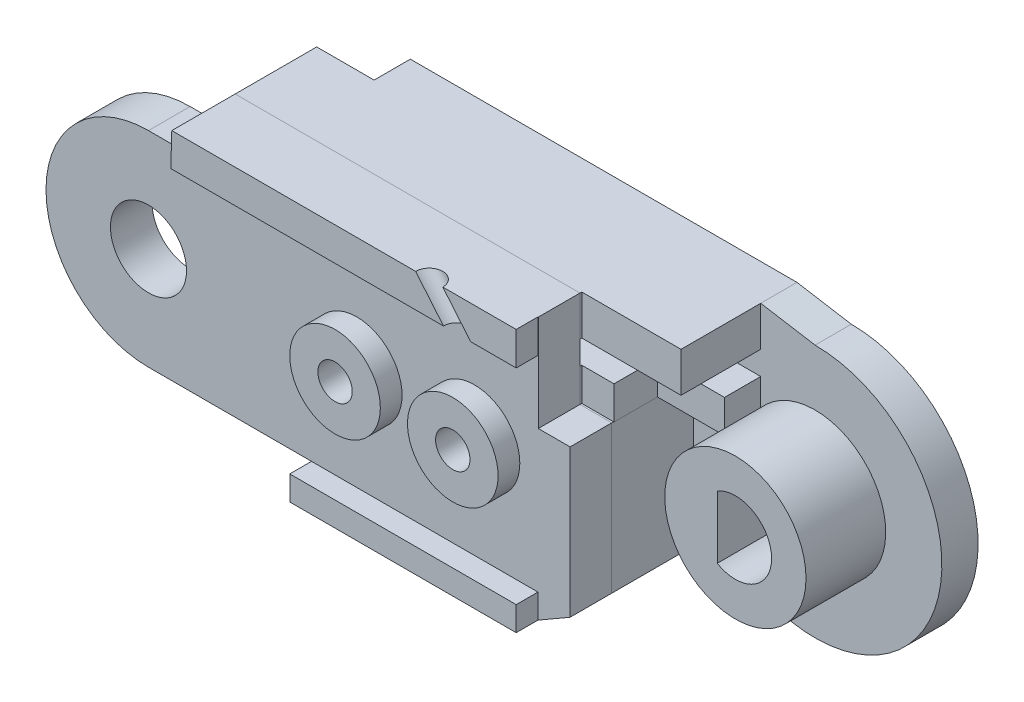
from build123d import *

# Parameters (mm, degrees)
BOSS_EXTRUDE1_DEPTH  = 2
BOSS_EXTRUDE6_DEPTH  = 4.5
CUT_EXTRUDE6_DEPTH   = 4.5
BOSS_EXTRUDE14_DEPTH = 2.3
SKETCH32_R           = 2.1
CUT_EXTRUDE7_DEPTH   = 2.3
SKETCH33_W           = 12.5
SKETCH33_H           = 1.343145751
BOSS_EXTRUDE15_DEPTH = 1.2
SKETCH35_W           = 5.479645997
SKETCH35_H           = 5.327993755
CUT_EXTRUDE8_DEPTH   = 2.4
SKETCH36_W           = 3.7
SKETCH36_H           = 1.827993755
CUT_EXTRUDE9_DEPTH   = 2.4
SKETCH37_R           = 3.9
BOSS_EXTRUDE16_DEPTH = 4.4
CUT_EXTRUDE10_DEPTH  = 7.4
SKETCH43_R           = 2.5
BOSS_EXTRUDE17_DEPTH = 1.2
SKETCH44_R           = 0.95
CUT_EXTRUDE11_DEPTH  = 11
SKETCH45_R           = 2
CUT_EXTRUDE12_DEPTH  = 4.5
SKETCH52_R           = 0.75
CUT_EXTRUDE13_DEPTH  = 10


with BuildPart() as part:
    # Sketch3 → Boss-Extrude1 (new body)
    with BuildSketch(Plane.XY):
        with BuildLine():
            Line((8, 0), (9, -2.5))
            Line((9, -2.5), (9, -7))
            Line((9, -7), (21.5, -7))
            Line((21.5, -7), (25.050252532, -4.949747468))
            ThreePointArc((25.050252532, -4.949747468), (36.467156728, -2.678784027), (30, 7))
            Line((30, 7), (27, 7.5))
            Line((27, 7.5), (5.656854249, 7.5))
            Line((5.656854249, 7.5), (5.656854249, 5.656854249))
            ThreePointArc((5.656854249, 5.656854249), (7.39103626, 3.061467459), (8, 0))
        make_face()
    extrude(amount=BOSS_EXTRUDE1_DEPTH)

    # Sketch22 → Boss-Extrude6 (add)
    with BuildSketch(Plane.XY.offset(2)):
        with BuildLine():
            Line((5.656854249, 5.656854249), (2.486790148, 5.656854249))
            Line((2.486790148, 5.656854249), (2.486790148, 7.5))
            Line((2.486790148, 7.5), (5.656854249, 7.5))
            Line((5.656854249, 7.5), (21.5, 7.5))
            Line((21.5, 7.5), (27, 7.5))
            Line((27, 7.5), (27, 2.172006245))
            Line((27, 2.172006245), (23.275126266, 2.172006245))
            Line((23.275126266, 2.172006245), (23.275126266, -5.974873734))
            Line((23.275126266, -5.974873734), (21.5, -7))
            Line((21.5, -7), (9, -7))
            Line((9, -7), (9, -2.5))
            Line((9, -2.5), (8, 0))
            ThreePointArc((8, 0), (7.39103626, 3.061467459), (5.656854249, 5.656854249))
        make_face()
    extrude(amount=BOSS_EXTRUDE6_DEPTH)

    # Sketch26 → Cut-Extrude6 (cut)
    with BuildSketch(Plane.XY.offset(2)):
        Polygon((18.098080448, 5.3), (2.530052458, 5.3), (2.530052458, 4), (18.098080448, 4), (27, 4), (27, 5.3), align=None)
    extrude(amount=CUT_EXTRUDE6_DEPTH, mode=Mode.SUBTRACT)


with BuildPart() as body_2:
    # Sketch31 → Boss-Extrude14 (new body)
    with BuildSketch(Plane.XY.offset(6.5)):
        with BuildLine():
            Line((2.432688066, 5.656854249), (0, 5.656854249))
            ThreePointArc((0, 5.656854249), (-5.656854249, 0), (0, -5.656854249))
            Line((0, -5.656854249), (9, -5.656854249))
            Line((9, -5.656854249), (9, -7))
            Line((9, -7), (21.5, -7))
            Line((21.5, -7), (23.275126266, -5.974873734))
            Line((23.275126266, -5.974873734), (23.275126266, 2.172006245))
            Line((23.275126266, 2.172006245), (27, 2.172006245))
            Line((27, 2.172006245), (27, 7.5))
            Line((27, 7.5), (2.486790148, 7.5))
            Line((2.486790148, 7.5), (2.432688066, 5.656854249))
        make_face()
    extrude(amount=BOSS_EXTRUDE14_DEPTH)

    # Sketch32 → Cut-Extrude7 (cut)
    with BuildSketch(Plane.XY.offset(8.8)):
        Circle(SKETCH32_R)
    extrude(amount=-CUT_EXTRUDE7_DEPTH, mode=Mode.SUBTRACT)

    # Sketch33 → Boss-Extrude15 (add)
    with BuildSketch(Plane.XY.offset(8.8)):
        with Locations((15.25, -6.328427125)):
            Rectangle(SKETCH33_W, SKETCH33_H)
        Polygon((2.486790148, 7.5), (21.5, 7.5), (21.5, 5.656854249), (2.432688066, 5.656854249), align=None)
    extrude(amount=BOSS_EXTRUDE15_DEPTH)


with BuildPart() as cut_extrude8_tool:
    # Sketch35 → Cut-Extrude8 (new body)
    with BuildSketch(Plane.XY.offset(8.8)):
        with Locations((24.260177002, 4.836003123)):
            Rectangle(SKETCH35_W, SKETCH35_H)
    extrude(amount=-CUT_EXTRUDE8_DEPTH)


with BuildPart() as part_1:
    add(part.part)

    # Cut-Extrude8: cut by cut_extrude8_tool
    add(cut_extrude8_tool.part, mode=Mode.SUBTRACT)

    # Sketch36 → Cut-Extrude9 (cut)
    with BuildSketch(Plane.XY.offset(6.4)):
        with Locations((25.15, 3.086003123)):
            Rectangle(SKETCH36_W, SKETCH36_H)
    extrude(amount=-CUT_EXTRUDE9_DEPTH, mode=Mode.SUBTRACT)

    # Sketch37 → Boss-Extrude16 (add)
    with BuildSketch(Plane.XY.offset(2)):
        with Locations((30, 0)):
            Circle(SKETCH37_R)
    extrude(amount=BOSS_EXTRUDE16_DEPTH)

    # Sketch39 → Cut-Extrude10 (cut, through all)
    with BuildSketch(Plane.XY.offset(6.4)):
        with BuildLine():
            Line((29, 1.732050808), (29, -1.732050808))
            ThreePointArc((29, -1.732050808), (32, 0), (29, 1.732050808))
        make_face()
    extrude(amount=-CUT_EXTRUDE10_DEPTH, mode=Mode.SUBTRACT)


with BuildPart() as body_2_1:
    add(body_2.part)

    # Cut-Extrude8: cut by cut_extrude8_tool
    add(cut_extrude8_tool.part, mode=Mode.SUBTRACT)

    # Sketch43 → Boss-Extrude17 (add)
    with BuildSketch(Plane.XY.offset(8.8)):
        with Locations((11.5, 0)):
            Circle(SKETCH43_R)
        with Locations((18, 0)):
            Circle(SKETCH43_R)
    extrude(amount=BOSS_EXTRUDE17_DEPTH)


with BuildPart() as cut_extrude11_tool:
    # Sketch44 → Cut-Extrude11 (new body, through all)
    with BuildSketch(Plane.XY.offset(10)):
        with Locations((11.5, 0)):
            Circle(SKETCH44_R)
        with Locations((18, 0)):
            Circle(SKETCH44_R)
    extrude(amount=-CUT_EXTRUDE11_DEPTH)


with BuildPart() as part_2:
    add(part_1.part)

    # Cut-Extrude11: cut by cut_extrude11_tool
    add(cut_extrude11_tool.part, mode=Mode.SUBTRACT)

    # Sketch45 → Cut-Extrude12 (cut)
    with BuildSketch(Plane(origin=(0, 0, 0), x_dir=(-1, 0, 0), z_dir=(0, 0, -1))):
        with Locations((-11.5, 0)):
            Circle(SKETCH45_R)
        with Locations((-18, 0)):
            Circle(SKETCH45_R)
    extrude(amount=-CUT_EXTRUDE12_DEPTH, mode=Mode.SUBTRACT)


with BuildPart() as body_2_2:
    add(body_2_1.part)

    # Cut-Extrude11: cut by cut_extrude11_tool
    add(cut_extrude11_tool.part, mode=Mode.SUBTRACT)

    # Sketch52 → Cut-Extrude13 (cut, along a direction that is not the sketch's normal)
    with BuildSketch(Plane.XZ.offset(-5.656854249)):
        with Locations((18.235476819, 10)):
            Circle(SKETCH52_R)
    extrude(amount=-CUT_EXTRUDE13_DEPTH, dir=(0.640410196, -0.76803306, 0), mode=Mode.SUBTRACT)


solid = Compound([part_2.part, body_2_2.part])
